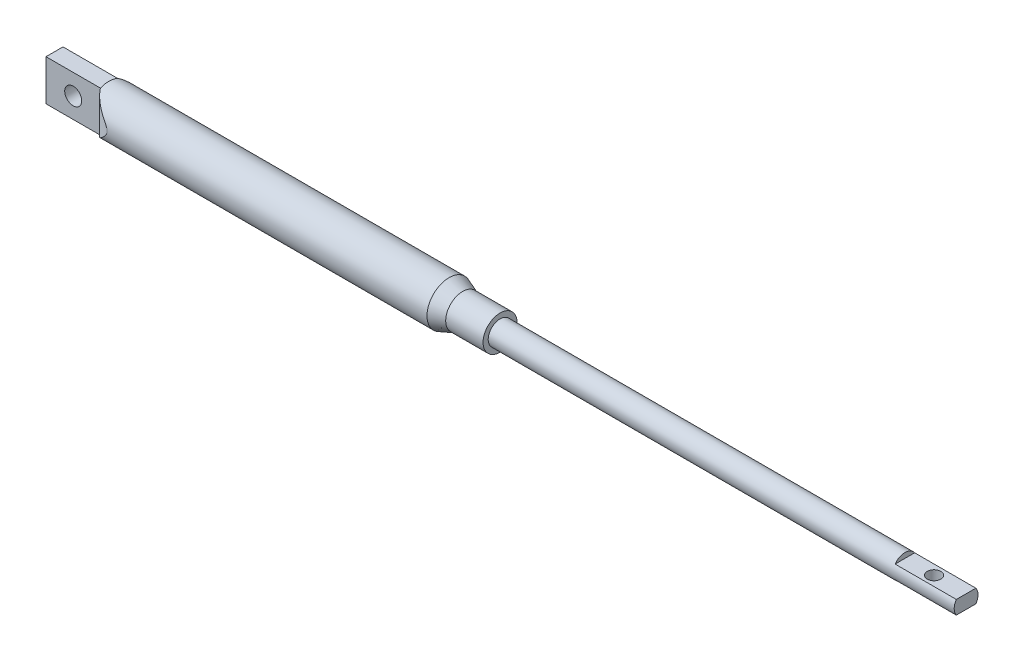
from build123d import *

# Parameters (mm, degrees)
CUT_EXTRUDE1_DEPTH = 21
SKETCH5_W          = 19.327905808
SKETCH5_H          = 9.031167277
CUT_EXTRUDE4_DEPTH = 25
CUT_EXTRUDE5_DEPTH = 5
SKETCH9_R          = 2
CUT_EXTRUDE6_DEPTH = 10
SKETCH10_R         = 2.5
CUT_EXTRUDE7_DEPTH = 10


with BuildPart() as part:
    # Sketch1 → Revolve1 (revolve)
    with BuildSketch(Plane(origin=(0, 0, 0), x_dir=(1, 0, 0), z_dir=(0, 1, 0))):
        Polygon((0, 0), (0, 6.5), (116, 6.5), (120, 5), (131, 5), (131, 3.5), (268, 3.5), (268, 0), align=None)
    revolve(axis=Axis((0, 0, 0), (1, 0, 0)))

    # Sketch2 → Cut-Extrude1 (cut, symmetric)
    with BuildSketch(Plane(origin=(0, 0, 0), x_dir=(1, 0, 0), z_dir=(0, 1, 0))):
        with BuildLine():
            Line((0, 6.5), (0, 2.5))
            Line((0, 2.5), (16, 2.5))
            ThreePointArc((16, 2.5), (18.611709863, 5.082435206), (22, 6.5))
            Line((22, 6.5), (0, 6.5))
        make_face()
        with BuildLine():
            Line((16, -2.5), (0, -2.5))
            Line((0, -2.5), (0, -6.5))
            Line((0, -6.5), (22, -6.5))
            ThreePointArc((22, -6.5), (18.611709863, -5.082435206), (16, -2.5))
        make_face()
    extrude(amount=CUT_EXTRUDE1_DEPTH, both=True, mode=Mode.SUBTRACT)

    # Sketch5 → Cut-Extrude4 (cut)
    with BuildSketch(Plane(origin=(0, 0, -2.5), x_dir=(-1, 0, 0), z_dir=(0, 0, -1))):
        with Locations((-6.336047096, 10.515583639)):
            Rectangle(SKETCH5_W, SKETCH5_H)
    extrude(amount=-CUT_EXTRUDE4_DEPTH, mode=Mode.SUBTRACT)

    # Sketch8 → Cut-Extrude5 (cut, symmetric)
    with BuildSketch(Plane.XY):
        Polygon((250, 2), (275.037154833, 2), (275.037154833, 6.622106016), (250, 7.374727948), align=None)
        Polygon((275.037154833, -10.204370032), (275.037154833, -2), (250, -2), (250, -8.806643588), align=None)
    extrude(amount=CUT_EXTRUDE5_DEPTH, both=True, mode=Mode.SUBTRACT)

    # Sketch9 → Cut-Extrude6 (cut)
    with BuildSketch(Plane(origin=(0, 2, 0), x_dir=(1, 0, 0), z_dir=(0, 1, 0))):
        with Locations((258.568042263, 0)):
            Circle(SKETCH9_R)
    extrude(amount=-CUT_EXTRUDE6_DEPTH, mode=Mode.SUBTRACT)

    # Sketch10 → Cut-Extrude7 (cut)
    with BuildSketch(Plane.XY.offset(2.5)):
        with Locations((8, 0)):
            Circle(SKETCH10_R)
    extrude(amount=-CUT_EXTRUDE7_DEPTH, mode=Mode.SUBTRACT)


solid = part.part
